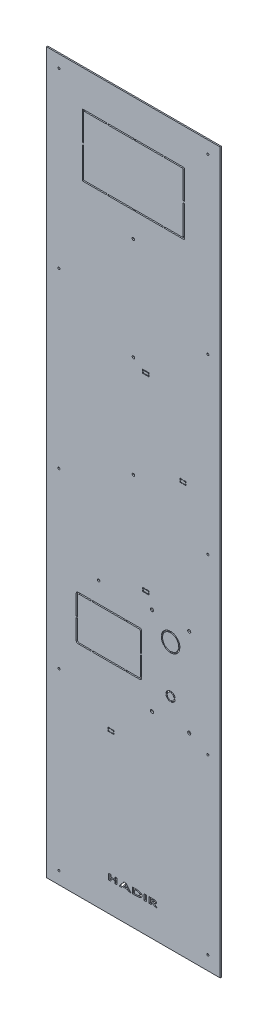
from build123d import *

# Parameters (mm, degrees)
BOSS_EXTRUDE2_DEPTH = 2
SKETCH3_R           = 2
SKETCH3_R_2         = 1.65
SKETCH3_R_3         = 2.5
SKETCH3_W           = 41.109833897
SKETCH3_H           = 2
SKETCH3_W_2         = 46.02015594
SKETCH3_W_3         = 52.483601223
CUT_EXTRUDE8_DEPTH  = 2
SKETCH4_W           = 3.627685547
SKETCH4_H           = 9.431982422
CUT_EXTRUDE9_DEPTH  = 2


with BuildPart() as part:
    # Sketch2 → Boss-Extrude2 (new body)
    with BuildSketch(Plane.XY):
        Polygon((-140, 680), (140, 680), (140, 580), (140, -480), (-140, -480), align=None)
    extrude(amount=BOSS_EXTRUDE2_DEPTH)

    # Sketch3 → Cut-Extrude8 (cut)
    with BuildSketch(Plane.XY):
        with Locations((-56.100012279, -23)):
            Circle(SKETCH3_R)
        with Locations((-120, -460)):
            Circle(SKETCH3_R_2)
        with Locations((120, -457.6)):
            Circle(SKETCH3_R_2)
        with Locations((90, -21)):
            Circle(SKETCH3_R_3)
        with Locations((89.999987721, -163)):
            Circle(SKETCH3_R_3)
        with Locations((29.999987721, -163)):
            Circle(SKETCH3_R_3)
        with Locations((29.999987721, -21)):
            Circle(SKETCH3_R_3)
        with Locations((-120, 660)):
            Circle(SKETCH3_R_2)
        with Locations((120, 660)):
            Circle(SKETCH3_R_2)
        with Locations((-120, 380.6)):
            Circle(SKETCH3_R_2)
        with Locations((120, 380.6)):
            Circle(SKETCH3_R_2)
        with Locations((120, -178.2)):
            Circle(SKETCH3_R_2)
        with Locations((-120, -178.2)):
            Circle(SKETCH3_R_2)
        with Locations((120, 101.2)):
            Circle(SKETCH3_R_2)
        with Locations((-120, 101.2)):
            Circle(SKETCH3_R_2)
        with Locations((0, 481.600002813)):
            Circle(SKETCH3_R)
        with Locations((0, 316.500002813)):
            Circle(SKETCH3_R)
        with Locations((0, 152.500002813)):
            Circle(SKETCH3_R)
        with BuildLine():
            Line((60, -36), (60.00001461, -38.000005513))
            ThreePointArc((60.00001461, -38.000005513), (64.40229458, -38.768082792), (68.284375962, -40.981554223))
            Line((68.284375962, -40.981554223), (69.558885127, -39.44026342))
            ThreePointArc((69.558885127, -39.44026342), (65.079558828, -36.88624879), (60, -36))
        make_face()
        with BuildLine():
            Line((59.000556004, -36.033342163), (59.122400034, -38.029662698))
            ThreePointArc((59.122400034, -38.029662698), (54.411111276, -39.262707552), (50.484141952, -42.142907772))
            Line((50.484141952, -42.142907772), (49.02015594, -40.780271897))
            ThreePointArc((49.02015594, -40.780271897), (53.557238864, -37.45413019), (59.000556004, -36.033342163))
        make_face()
        with BuildLine():
            Line((74.933661101, -52.409179713), (72.94252229, -52.221291353))
            ThreePointArc((72.94252229, -52.221291353), (72.168738974, -46.425929265), (68.933492433, -41.555801733))
            Line((68.933492433, -41.555801733), (70.307864595, -40.102856625))
            ThreePointArc((70.307864595, -40.102856625), (74.040835155, -45.722230337), (74.933661101, -52.409179713))
        make_face()
        with BuildLine():
            Line((74.806582661, -53.401072383), (72.832387322, -53.080932568))
            ThreePointArc((72.832387322, -53.080932568), (71.39953375, -57.249087296), (68.656303527, -60.698909196))
            Line((68.656303527, -60.698909196), (69.988033372, -62.191040241))
            ThreePointArc((69.988033372, -62.191040241), (73.153293496, -58.210477998), (74.806582661, -53.401072383))
        make_face()
        with BuildLine():
            Line((60, -66.000017478), (60.00001461, -64.000008617))
            ThreePointArc((60.00001461, -64.000008617), (64.224735631, -63.294386783), (67.990832799, -61.254121606))
            Line((67.990832799, -61.254121606), (69.220183567, -62.831670149))
            ThreePointArc((69.220183567, -62.831670149), (64.874684241, -65.185832318), (60, -66.000017478))
        make_face()
        with BuildLine():
            Line((59.000541044, -65.96712681), (59.000541044, -63.961530623))
            ThreePointArc((59.000541044, -63.961530623), (54.566773379, -62.810169218), (50.807625358, -60.192396318))
            Line((50.807625358, -60.192396318), (49.393414477, -61.606607198))
            ThreePointArc((49.393414477, -61.606607198), (53.800950165, -64.659397705), (59.000541044, -65.96712681))
        make_face()
        with BuildLine():
            Line((60.980600924, -119.564383163), (60.71910407, -121.54721432))
            ThreePointArc((60.71910407, -121.54721432), (63.889075017, -123.110912704), (65.452773401, -126.280883651))
            Line((65.452773401, -126.280883651), (67.435604557, -126.019386797))
            ThreePointArc((67.435604557, -126.019386797), (65.30328858, -121.696699141), (60.980600924, -119.564383163))
        make_face()
        with BuildLine():
            Line((58.987382691, -119.568672322), (59.257410699, -121.550359703))
            ThreePointArc((59.257410699, -121.550359703), (56.102540613, -123.119290524), (54.54720204, -126.280883651))
            Line((54.54720204, -126.280883651), (52.564370884, -126.019386797))
            ThreePointArc((52.564370884, -126.019386797), (54.685287119, -121.708123441), (58.987382691, -119.568672322))
        make_face()
        with BuildLine():
            Line((67.435604557, -127.980613203), (65.452773401, -127.719116349))
            ThreePointArc((65.452773401, -127.719116349), (63.889075017, -130.889087296), (60.71910407, -132.45278568))
            Line((60.71910407, -132.45278568), (60.980600924, -134.435616836))
            ThreePointArc((60.980600924, -134.435616836), (65.303288579, -132.303300859), (67.435604557, -127.980613203))
        make_face()
        with BuildLine():
            Line((52.564370884, -127.980613203), (54.54720204, -127.719116349))
            ThreePointArc((54.54720204, -127.719116349), (56.102540613, -130.880709476), (59.257410699, -132.449640297))
            Line((59.257410699, -132.449640297), (58.987382691, -134.431327677))
            ThreePointArc((58.987382691, -134.431327677), (54.685287119, -132.291876559), (52.564370884, -127.980613203))
        make_face()
        with BuildLine():
            Line((45.263274159, -48.201990118), (47.228183224, -48.575061007))
            ThreePointArc((47.228183224, -48.575061007), (48.212106329, -45.518651513), (49.915143539, -42.796628748))
            Line((49.915143539, -42.796628748), (48.363618413, -41.534565259))
            ThreePointArc((48.363618413, -41.534565259), (46.398572229, -44.675361768), (45.263274159, -48.201990118))
        make_face()
        with BuildLine():
            Line((45.108152373, -49.201990118), (47.093744677, -49.441726999))
            ThreePointArc((47.093744677, -49.441726999), (47.511194531, -54.609634938), (49.915144959, -59.203387129))
            Line((49.915144959, -59.203387129), (48.363618413, -60.46545222))
            ThreePointArc((48.363618413, -60.46545222), (45.589825437, -55.164965615), (45.108152373, -49.201990118))
        make_face()
        Polygon((-32.100012279, -221.1), (-35.600012279, -221.1), (-35.600012279, -220.1), (-31.100012279, -220.1), (-31.100012279, -222.5), (-32.100012279, -222.5), align=None)
        Polygon((-40.100012279, -221.1), (-40.100012279, -222.5), (-41.100012279, -222.5), (-41.100012279, -220.1), (-36.600012279, -220.1), (-36.600012279, -221.1), align=None)
        Polygon((24, 306.400002813), (24, 305.000002813), (25, 305.000002813), (25, 307.400002813), (20.5, 307.400002813), (20.5, 306.400002813), align=None)
        Polygon((-31.100012279, -225.9), (-35.600012279, -225.9), (-35.600012279, -224.9), (-32.100012279, -224.9), (-32.100012279, -223.5), (-31.100012279, -223.5), align=None)
        Polygon((24, 1.9), (24, 0.5), (25, 0.5), (25, 2.9), (20.5, 2.9), (20.5, 1.9), align=None)
        Polygon((-40.100012279, -223.5), (-40.100012279, -224.9), (-36.600012279, -224.9), (-36.600012279, -225.9), (-41.100012279, -225.9), (-41.100012279, -223.5), align=None)
        with BuildLine():
            Line((81.2, 622.2), (50.00515594, 622.2))
            Line((50.00515594, 622.2), (50.00515594, 620.2))
            Line((50.00515594, 620.2), (79.2, 620.2))
            ThreePointArc((79.2, 620.2), (79.907106781, 619.907106781), (80.2, 619.2))
            Line((80.2, 619.2), (80.2, 575.26))
            Line((80.2, 575.26), (82.2, 575.26))
            Line((82.2, 575.26), (82.2, 621.2))
            ThreePointArc((82.2, 621.2), (81.907106781, 621.907106781), (81.2, 622.2))
        make_face()
        with BuildLine():
            Line((81.2, 521.6), (50.00515594, 521.6))
            Line((50.00515594, 521.6), (50.00515594, 523.6))
            Line((50.00515594, 523.6), (79.2, 523.6))
            ThreePointArc((79.2, 523.6), (79.907106781, 523.892893219), (80.2, 524.6))
            Line((80.2, 524.6), (80.2, 572.28))
            Line((80.2, 572.28), (82.2, 572.28))
            Line((82.2, 572.28), (82.2, 522.6))
            ThreePointArc((82.2, 522.6), (81.907106781, 521.892893219), (81.2, 521.6))
        make_face()
        with BuildLine():
            Line((-82.2, 522.6), (-82.2, 572.28))
            Line((-82.2, 572.28), (-80.2, 572.28))
            Line((-80.2, 572.28), (-80.2, 524.6))
            ThreePointArc((-80.2, 524.6), (-79.907106781, 523.892893219), (-79.2, 523.6))
            Line((-79.2, 523.6), (-43.124833897, 523.6))
            Line((-43.124833897, 523.6), (-43.124833897, 521.6))
            Line((-43.124833897, 521.6), (-81.2, 521.6))
            ThreePointArc((-81.2, 521.6), (-81.907106781, 521.892893219), (-82.2, 522.6))
        make_face()
        with Locations((-20.569916949, 522.6)):
            Rectangle(SKETCH3_W, SKETCH3_H)
        with Locations((24.99507797, 621.2)):
            Rectangle(SKETCH3_W_2, SKETCH3_H)
        with Locations((-20.569916949, 621.2)):
            Rectangle(SKETCH3_W, SKETCH3_H)
        with Locations((24.99507797, 522.6)):
            Rectangle(SKETCH3_W_2, SKETCH3_H)
        with BuildLine():
            Line((-43.124833897, 622.2), (-43.124833897, 620.2))
            Line((-43.124833897, 620.2), (-79.2, 620.2))
            ThreePointArc((-79.2, 620.2), (-79.907106781, 619.907106781), (-80.2, 619.2))
            Line((-80.2, 619.2), (-80.2, 575.26))
            Line((-80.2, 575.26), (-82.2, 575.26))
            Line((-82.2, 575.26), (-82.2, 621.2))
            ThreePointArc((-82.2, 621.2), (-81.907106781, 621.907106781), (-81.2, 622.2))
            Line((-81.2, 622.2), (-43.124833897, 622.2))
        make_face()
        with BuildLine():
            Line((-11.516442734, -128), (10.479987721, -128))
            ThreePointArc((10.479987721, -128), (12.601308064, -127.121320344), (13.479987721, -125))
            Line((13.479987721, -125), (13.479987721, -93))
            Line((13.479987721, -93), (11.479987721, -93))
            Line((11.479987721, -93), (11.479987721, -123))
            ThreePointArc((11.479987721, -123), (10.601308064, -125.121320344), (8.479987721, -126))
            Line((8.479987721, -126), (-11.516442734, -126))
            Line((-11.516442734, -126), (-11.516442734, -128))
        make_face()
        with BuildLine():
            Line((-68.000043957, -126), (-87.120012279, -126))
            ThreePointArc((-87.120012279, -126), (-89.241332623, -125.121320344), (-90.120012279, -123))
            Line((-90.120012279, -123), (-90.120012279, -93))
            Line((-90.120012279, -93), (-92.120012279, -93))
            Line((-92.120012279, -93), (-92.120012279, -125))
            ThreePointArc((-92.120012279, -125), (-91.241332623, -127.121320344), (-89.120012279, -128))
            Line((-89.120012279, -128), (-68.000043957, -128))
            Line((-68.000043957, -128), (-68.000043957, -126))
        make_face()
        Polygon((84, 184.400002813), (84, 183.000002813), (85, 183.000002813), (85, 185.400002813), (80.5, 185.400002813), (80.5, 184.400002813), align=None)
        with BuildLine():
            Line((-11.516442734, -56), (-11.516442734, -58))
            Line((-11.516442734, -58), (8.479987721, -58))
            ThreePointArc((8.479987721, -58), (10.601308064, -58.878679656), (11.479987721, -61))
            Line((11.479987721, -61), (11.479987721, -91))
            Line((11.479987721, -91), (13.479987721, -91))
            Line((13.479987721, -91), (13.479987721, -59))
            ThreePointArc((13.479987721, -59), (12.601308064, -56.878679656), (10.479987721, -56))
            Line((10.479987721, -56), (-11.516442734, -56))
        make_face()
        with Locations((-39.758243345, -57)):
            Rectangle(SKETCH3_W_3, SKETCH3_H)
        with BuildLine():
            Line((-90.120012279, -91), (-92.120012279, -91))
            Line((-92.120012279, -91), (-92.120012279, -59))
            ThreePointArc((-92.120012279, -59), (-91.241332623, -56.878679656), (-89.120012279, -56))
            Line((-89.120012279, -56), (-68.000043957, -56))
            Line((-68.000043957, -56), (-68.000043957, -58))
            Line((-68.000043957, -58), (-87.120012279, -58))
            ThreePointArc((-87.120012279, -58), (-89.241332623, -58.878679656), (-90.120012279, -61))
            Line((-90.120012279, -61), (-90.120012279, -91))
        make_face()
        with Locations((-39.758243345, -127)):
            Rectangle(SKETCH3_W_3, SKETCH3_H)
        Polygon((25, 301.600002813), (20.5, 301.600002813), (20.5, 302.600002813), (24, 302.600002813), (24, 304.000002813), (25, 304.000002813), align=None)
        Polygon((15, 307.400002813), (15, 305.000002813), (16, 305.000002813), (16, 306.400002813), (19.5, 306.400002813), (19.5, 307.400002813), align=None)
        Polygon((19.5, 302.600002813), (16, 302.600002813), (16, 304.000002813), (15, 304.000002813), (15, 301.600002813), (19.5, 301.600002813), align=None)
        Polygon((25, -2.9), (20.5, -2.9), (20.5, -1.9), (24, -1.9), (24, -0.5), (25, -0.5), align=None)
        Polygon((15, 2.9), (15, 0.5), (16, 0.5), (16, 1.9), (19.5, 1.9), (19.5, 2.9), align=None)
        Polygon((85, 179.600002813), (80.5, 179.600002813), (80.5, 180.600002813), (84, 180.600002813), (84, 182.040002813), (85, 182.040002813), align=None)
        Polygon((75, 185.400002813), (75, 183.000002813), (76, 183.000002813), (76, 184.400002813), (79.5, 184.400002813), (79.5, 185.400002813), align=None)
        Polygon((19.5, -2.9), (15, -2.9), (15, -0.5), (16, -0.5), (16, -1.9), (19.5, -1.9), align=None)
        Polygon((79.5, 180.600002813), (76, 180.600002813), (76, 182.040002813), (75, 182.040002813), (75, 179.600002813), (79.5, 179.600002813), align=None)
    extrude(amount=CUT_EXTRUDE8_DEPTH, mode=Mode.SUBTRACT)

    # Sketch4 → Cut-Extrude9 (cut)
    with BuildSketch(Plane.XY):
        Polygon((-40.061027035, -423.68864967), (-36.433341488, -423.68864967), (-36.433341488, -427.316335217), (-29.6616618, -427.316335217), (-29.6616618, -423.68864967), (-26.033976253, -423.68864967), (-26.033976253, -433.120632092), (-29.6616618, -433.120632092), (-29.6616618, -429.009255138), (-36.433341488, -429.009255138), (-36.433341488, -433.120632092), (-40.061027035, -433.120632092), align=None)
        Polygon((-15.491015133, -423.68864967), (-11.785863384, -423.68864967), (-4.207401546, -433.120632092), (-8.093937572, -433.120632092), (-9.611141476, -431.185866467), (-17.667626461, -431.185866467), (-19.186719784, -433.120632092), (-23.07136639, -433.120632092), align=None)
        Polygon((-13.639383968, -426.218582455), (-16.339364513, -429.492946545), (-10.939403423, -429.492946545), align=None, mode=Mode.SUBTRACT)
        with BuildLine():
            Line((-1.486637386, -423.68864967), (2.95160915, -423.68864967))
            add(Edge.make_bspline(
                [(2.95160915, -423.68864967), (3.127327275, -423.688984823), (3.473734374, -423.689645537), (3.984515834, -423.695685686), (4.478350403, -423.704067328), (4.953790876, -423.720625979), (5.412412885, -423.736176275), (5.853899353, -423.759315101), (6.278321351, -423.786325767), (6.685408819, -423.813231538), (7.075154297, -423.848339144), (7.448276564, -423.884635264), (7.80385513, -423.929478174), (8.141659663, -423.9739191), (8.462517036, -424.022529563), (8.765710611, -424.078458407), (9.053004398, -424.133230716), (9.408853454, -424.217203151), (9.832496402, -424.331407802), (10.320683059, -424.487008028), (10.784783877, -424.666108186), (11.227457581, -424.861052742), (11.646240214, -425.079226502), (12.041481068, -425.316854837), (12.41295266, -425.57550624), (12.761699089, -425.848567784), (13.078282801, -426.138685314), (13.354690295, -426.444469014), (13.588707038, -426.762363789), (13.779621562, -427.093773412), (13.928074195, -427.437460575), (14.033953451, -427.793165455), (14.101374841, -428.160870938), (14.108705223, -428.410647325), (14.112410465, -428.536900249)],
                knots=[0, 0, 0, 0, 0.000527151, 0.001039216, 0.001532444, 0.002008818, 0.002466374, 0.002909079, 0.00333502, 0.003742233, 0.004132937, 0.004508945, 0.004866805, 0.005208037, 0.005531106, 0.005840198, 0.00613293, 0.006408377, 0.006936837, 0.007448912, 0.007944721, 0.008428546, 0.008899258, 0.009360357, 0.009811102, 0.010256384, 0.010688268, 0.011097649, 0.011491052, 0.011870238, 0.012242626, 0.01261145, 0.012981723, 0.013360179, 0.013360179, 0.013360179, 0.013360179], degree=3))
            add(Edge.make_bspline(
                [(14.112410465, -428.536900249), (14.110484441, -428.627098675), (14.106670519, -428.805709991), (14.068368459, -429.070447547), (14.01094765, -429.330126093), (13.926475466, -429.583856009), (13.820895386, -429.832895641), (13.688582279, -430.075084434), (13.536383202, -430.313918356), (13.357640248, -430.543805465), (13.158773745, -430.765946054), (12.944145359, -430.981660126), (12.710273523, -431.18637538), (12.458359384, -431.381074155), (12.188485584, -431.566142684), (11.899297101, -431.739806402), (11.594237531, -431.906411793), (11.160697439, -432.112544177), (10.593854146, -432.343941389), (9.88567113, -432.57700142), (9.149332163, -432.761814491), (8.579370263, -432.864239729), (8.18305888, -432.919922558), (7.962672228, -432.946711485), (7.723694997, -432.968078666), (7.467474215, -432.991456007), (7.193458078, -433.011899786), (6.902471813, -433.030730287), (6.593858222, -433.047893384), (6.266914688, -433.062122184), (5.92187515, -433.078518856), (5.559031842, -433.088808208), (5.178635285, -433.098718654), (4.780563246, -433.105247047), (4.364929275, -433.114380819), (3.931583196, -433.116357075), (3.480657457, -433.121767599), (3.173932727, -433.121015225), (3.017738834, -433.120632092)],
                knots=[0, 0, 0, 0, 0.000270425, 0.000535496, 0.000800891, 0.001067373, 0.001336554, 0.0016113, 0.001894316, 0.002185311, 0.00248375, 0.002788363, 0.003097633, 0.003415472, 0.003743018, 0.004078718, 0.004427049, 0.004785366, 0.00551833, 0.006262207, 0.007020156, 0.007793984, 0.007998128, 0.008220768, 0.008459912, 0.008717871, 0.008992624, 0.009284207, 0.009592652, 0.009919871, 0.010265965, 0.010628911, 0.011008801, 0.01140754, 0.011823281, 0.012255975, 0.012707562, 0.013176138, 0.013176138, 0.013176138, 0.013176138], degree=3))
            Line((3.017738834, -433.120632092), (-1.486637386, -433.120632092))
            Line((-1.486637386, -433.120632092), (-1.486637386, -423.68864967))
        make_face()
        with BuildLine():
            Line((2.141048161, -425.381569592), (2.141048161, -431.42771217))
            Line((2.141048161, -431.42771217), (3.934107319, -431.42771217))
            add(Edge.make_bspline(
                [(3.934107319, -431.42771217), (4.146998468, -431.427503063), (4.55772495, -431.427099638), (5.150970696, -431.409565982), (5.699832088, -431.391723109), (6.202391293, -431.358279757), (6.660193029, -431.321072779), (7.071211746, -431.268296371), (7.438911053, -431.21488409), (7.765171715, -431.145052283), (8.062884447, -431.066400653), (8.341503841, -430.975771473), (8.607161326, -430.874589528), (8.857394385, -430.757810165), (9.09532529, -430.632351579), (9.319648148, -430.493792486), (9.529971516, -430.342329842), (9.725290704, -430.179016328), (9.90432306, -430.005892076), (10.059146754, -429.820748384), (10.191202686, -429.626014684), (10.300213506, -429.422067721), (10.380436068, -429.205919391), (10.442319526, -428.981868164), (10.478664669, -428.747184883), (10.482690582, -428.587406984), (10.484724918, -428.506669537)],
                knots=[0, 0, 0, 0, 0.000638635, 0.001232105, 0.001780431, 0.002285927, 0.002743003, 0.003158044, 0.003528948, 0.003857272, 0.004158378, 0.004452352, 0.004735865, 0.005010612, 0.005280243, 0.00554241, 0.005800929, 0.006057118, 0.006305633, 0.006547065, 0.00677974, 0.007010473, 0.007238913, 0.007469918, 0.00770694, 0.007949051, 0.007949051, 0.007949051, 0.007949051], degree=3))
            add(Edge.make_bspline(
                [(10.484724918, -428.506669537), (10.483162085, -428.4436347), (10.480090322, -428.319739135), (10.459032776, -428.136374978), (10.422989635, -427.958929616), (10.373280771, -427.786008048), (10.312002089, -427.617758209), (10.233094203, -427.455735831), (10.140412821, -427.299355736), (10.034967394, -427.147814744), (9.913482642, -427.003199871), (9.780789134, -426.861287444), (9.630334181, -426.727652105), (9.466985972, -426.599174986), (9.291235272, -426.473642042), (9.100058307, -426.355540875), (8.895597455, -426.241093396), (8.751905731, -426.17243877), (8.678439823, -426.137337414)],
                knots=[0, 0, 0, 0, 0.000189093, 0.000371664, 0.000552861, 0.000731679, 0.000911024, 0.001089332, 0.001271443, 0.001455949, 0.001642467, 0.001837599, 0.002038287, 0.002245435, 0.002460903, 0.002685816, 0.002919249, 0.003163452, 0.003163452, 0.003163452, 0.003163452], degree=3))
            add(Edge.make_bspline(
                [(8.678439823, -426.137337414), (8.608120409, -426.10658828), (8.4636369, -426.043408817), (8.237146977, -425.956333197), (7.994603018, -425.877699001), (7.737475128, -425.804000384), (7.464583061, -425.736101773), (7.17673991, -425.673650497), (6.872627983, -425.620014631), (6.554241401, -425.567708302), (6.219307042, -425.526126542), (5.869387448, -425.484831668), (5.503816969, -425.4540879), (5.122765179, -425.427224308), (4.726537323, -425.406933574), (4.314625679, -425.391145077), (3.88752041, -425.384727301), (3.597791205, -425.382634253), (3.450415913, -425.381569592)],
                knots=[0, 0, 0, 0, 0.00023023, 0.000473048, 0.00072758, 0.000994898, 0.001275348, 0.001571077, 0.00187831, 0.002201671, 0.00253891, 0.002890697, 0.003258649, 0.003639343, 0.004036665, 0.004448836, 0.004875911, 0.005318052, 0.005318052, 0.005318052, 0.005318052], degree=3))
            Line((3.450415913, -425.381569592), (2.141048161, -425.381569592))
        make_face(mode=Mode.SUBTRACT)
        with Locations((18.949324528, -428.404640881)):
            Rectangle(SKETCH4_W, SKETCH4_H)
        with BuildLine():
            Line((25.479158512, -423.68864967), (29.465833775, -423.68864967))
            add(Edge.make_bspline(
                [(29.465833775, -423.68864967), (29.599981747, -423.689364143), (29.863239385, -423.690766256), (30.250595035, -423.691389972), (30.622806042, -423.697815745), (30.980548006, -423.705089853), (31.323160558, -423.714743859), (31.651372201, -423.725102256), (31.96489456, -423.741771258), (32.264223846, -423.755147652), (32.548204916, -423.774875546), (32.817157845, -423.795469182), (33.071632762, -423.818007273), (33.311625483, -423.842445631), (33.537122555, -423.868927877), (33.747541168, -423.896995872), (33.943672138, -423.926699181), (34.181933284, -423.972240094), (34.463783083, -424.032958731), (34.786177735, -424.117297658), (35.091373182, -424.213832883), (35.379166008, -424.32123663), (35.650251427, -424.440804676), (35.905270256, -424.57006067), (36.142402321, -424.712499419), (36.361349169, -424.864655794), (36.5588835, -425.025902521), (36.73349202, -425.194347525), (36.878992173, -425.372516519), (36.999968932, -425.556896556), (37.093615603, -425.749241346), (37.159722433, -425.948734603), (37.201464863, -426.155760237), (37.206248882, -426.296480053), (37.208675114, -426.3678466)],
                knots=[0, 0, 0, 0, 0.000402451, 0.000789786, 0.001162045, 0.001519225, 0.00186323, 0.002190296, 0.002504303, 0.002805101, 0.003089143, 0.003358245, 0.003614322, 0.003855532, 0.004081924, 0.004295428, 0.004492372, 0.004676917, 0.005023058, 0.005357149, 0.005676242, 0.005982963, 0.006278209, 0.006564666, 0.006840094, 0.007107412, 0.007363852, 0.00760435, 0.007833936, 0.008052473, 0.008264576, 0.008473697, 0.008681576, 0.00889549, 0.00889549, 0.00889549, 0.00889549], degree=3))
            add(Edge.make_bspline(
                [(37.208675114, -426.3678466), (37.205735808, -426.442387543), (37.199930607, -426.589607703), (37.154675509, -426.805083861), (37.082971794, -427.011603557), (36.978794816, -427.208239558), (36.846026775, -427.394964751), (36.684499814, -427.57256761), (36.495164297, -427.741337298), (36.273374051, -427.896818652), (36.025783344, -428.047515026), (35.746070933, -428.183265045), (35.43989505, -428.315090123), (35.101864226, -428.432254999), (34.735855747, -428.543878059), (34.339847151, -428.645391881), (33.915062122, -428.738030445), (33.620868067, -428.789866306), (33.469513813, -428.816534344)],
                knots=[0, 0, 0, 0, 0.000223463, 0.000441345, 0.000657665, 0.000877399, 0.001106487, 0.001343268, 0.001596204, 0.001865703, 0.002154741, 0.002464847, 0.002797541, 0.003154301, 0.003537425, 0.003945281, 0.004380365, 0.004841383, 0.004841383, 0.004841383, 0.004841383], degree=3))
            Line((33.469513813, -428.816534344), (38.1155965, -433.120632092))
            Line((38.1155965, -433.120632092), (34.030671421, -433.120632092))
            Line((34.030671421, -433.120632092), (29.592424885, -429.009255138))
            Line((29.592424885, -429.009255138), (29.106844059, -429.009255138))
            Line((29.106844059, -429.009255138), (29.106844059, -433.120632092))
            Line((29.106844059, -433.120632092), (25.479158512, -433.120632092))
            Line((25.479158512, -433.120632092), (25.479158512, -423.68864967))
        make_face()
        with BuildLine():
            Line((29.106844059, -427.316335217), (30.325519672, -427.316335217))
            add(Edge.make_bspline(
                [(30.325519672, -427.316335217), (30.474155201, -427.315417541), (30.759491203, -427.313655876), (31.169665442, -427.305688745), (31.543807664, -427.286095112), (31.881470279, -427.261871781), (32.183700284, -427.233394146), (32.448900623, -427.193349358), (32.679001939, -427.149635517), (32.874825984, -427.096426327), (33.042086483, -427.035921589), (33.185426688, -426.966638264), (33.306176773, -426.885855169), (33.408184393, -426.79852123), (33.485260756, -426.697497324), (33.541121486, -426.588948134), (33.574636243, -426.469926857), (33.578829583, -426.387586814), (33.580989567, -426.345173565)],
                knots=[0, 0, 0, 0, 0.000445919, 0.000856032, 0.001230614, 0.001569711, 0.001871646, 0.002140992, 0.002374066, 0.002573916, 0.002749062, 0.002907075, 0.003050135, 0.003183977, 0.003307933, 0.003428767, 0.003548413, 0.003675511, 0.003675511, 0.003675511, 0.003675511], degree=3))
            add(Edge.make_bspline(
                [(33.580989567, -426.345173565), (33.577280321, -426.294633128), (33.569764288, -426.192223201), (33.496710639, -426.04858207), (33.384722547, -425.916647156), (33.229746774, -425.80089608), (33.042098335, -425.695780012), (32.823270587, -425.605303252), (32.574790554, -425.5329912), (32.345280154, -425.485814998), (32.135279115, -425.4570355), (31.944439971, -425.436028935), (31.723793119, -425.42030018), (31.472549203, -425.404427068), (31.190939764, -425.393847533), (30.878529029, -425.386243537), (30.536510616, -425.383093036), (30.298438084, -425.382091529), (30.174366108, -425.381569592)],
                knots=[0, 0, 0, 0, 0.000150704, 0.000305371, 0.000473019, 0.000666904, 0.000881808, 0.001117259, 0.001375509, 0.001657127, 0.001819321, 0.00201128, 0.002232995, 0.002482856, 0.002766496, 0.003078342, 0.003420348, 0.003792568, 0.003792568, 0.003792568, 0.003792568], degree=3))
            Line((30.174366108, -425.381569592), (29.106844059, -425.381569592))
            Line((29.106844059, -425.381569592), (29.106844059, -427.316335217))
        make_face(mode=Mode.SUBTRACT)
    extrude(amount=CUT_EXTRUDE9_DEPTH, mode=Mode.SUBTRACT)


solid = part.part
